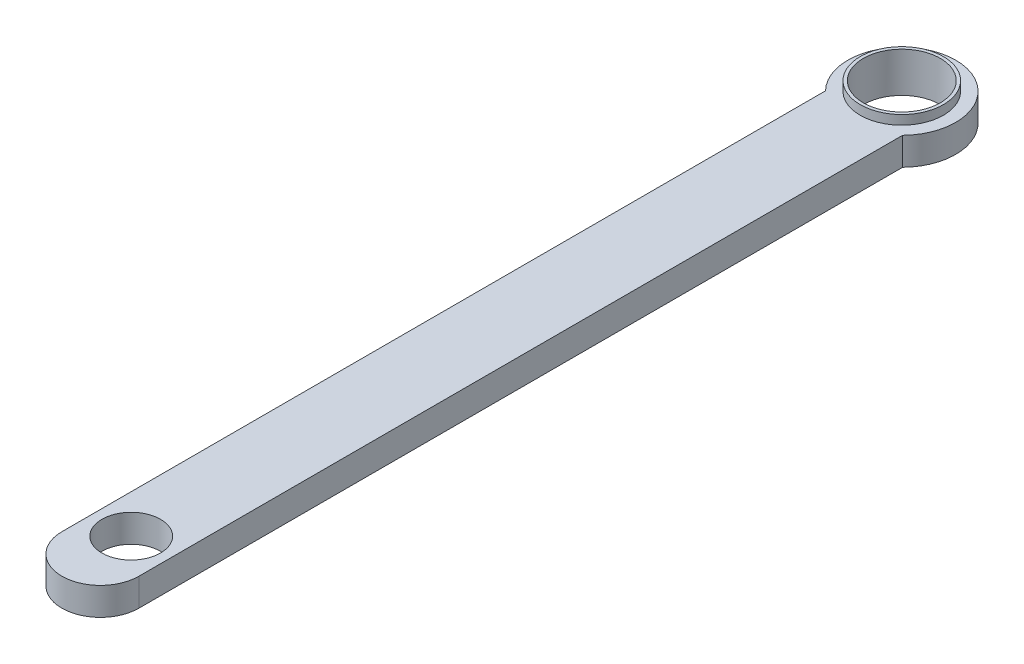
from build123d import *

# Parameters (mm, degrees)
EXTRUDE_1_DEPTH     = 9
SKETCH_2_R          = 12.5
CUT_EXTRUDE_1_DEPTH = 10
SKETCH_3_R          = 13.5
SKETCH_3_R_2        = 12.5
EXTRUDE_2_DEPTH     = 3
SKETCH_4_R          = 13.5
SKETCH_4_R_2        = 12.5
EXTRUDE_3_DEPTH     = 1
SKETCH_5_R          = 9.5
CUT_EXTRUDE_2_DEPTH = 11


with BuildPart() as part:
    # 스케치1 → 보스-돌출1 (new body)
    with BuildSketch(Plane(origin=(0, 0, 0), x_dir=(1, 0, 0), z_dir=(0, 1, 0))):
        with BuildLine():
            Line((-12.5, -260), (-12.5, -12.247448714))
            ThreePointArc((-12.5, -12.247448714), (0, 17.5), (12.5, -12.247448714))
            Line((12.5, -12.247448714), (12.5, -260))
            ThreePointArc((12.5, -260), (0, -272.5), (-12.5, -260))
        make_face()
    extrude(amount=EXTRUDE_1_DEPTH)

    # 스케치2 → 컷-돌출1 (cut, through all)
    with BuildSketch(Plane(origin=(0, 9, 0), x_dir=(1, 0, 0), z_dir=(0, 1, 0))):
        Circle(SKETCH_2_R)
    extrude(amount=-CUT_EXTRUDE_1_DEPTH, mode=Mode.SUBTRACT)

    # 스케치3 → 보스-돌출2 (add)
    with BuildSketch(Plane(origin=(0, 9, 0), x_dir=(1, 0, 0), z_dir=(0, 1, 0))):
        Circle(SKETCH_3_R)
        Circle(SKETCH_3_R_2, mode=Mode.SUBTRACT)
    extrude(amount=EXTRUDE_2_DEPTH)

    # 스케치4 → 보스-돌출3 (add)
    with BuildSketch(Plane.XZ):
        Circle(SKETCH_4_R)
        Circle(SKETCH_4_R_2, mode=Mode.SUBTRACT)
    extrude(amount=EXTRUDE_3_DEPTH)

    # 스케치5 → 컷-돌출2 (cut, through all)
    with BuildSketch(Plane(origin=(0, 9, 0), x_dir=(1, 0, 0), z_dir=(0, 1, 0))):
        with Locations((0, -250)):
            Circle(SKETCH_5_R)
    extrude(amount=-CUT_EXTRUDE_2_DEPTH, mode=Mode.SUBTRACT)


solid = part.part
